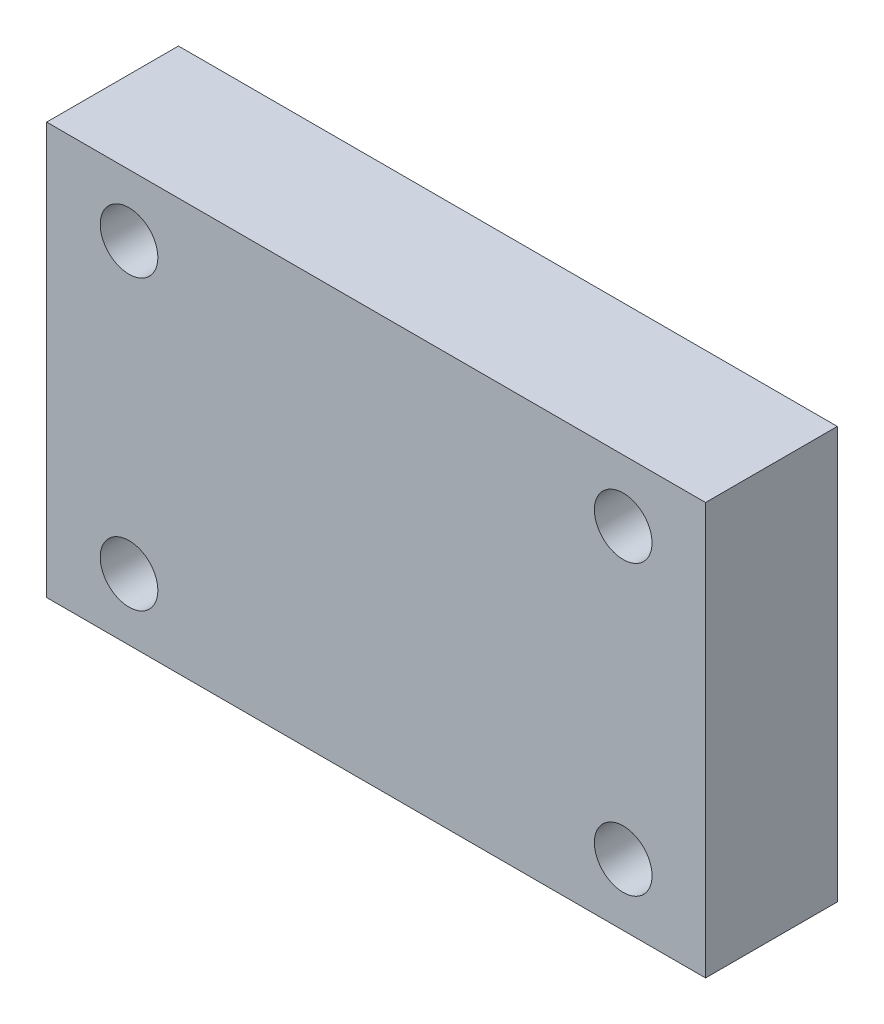
from build123d import *

# Parameters (mm, degrees)
ESQUISSE1_W             = 80
ESQUISSE1_H             = 50
BOSS_EXTRU_1_DEPTH      = 8
ESQUISSE2_R             = 3.5
ENL_V_MAT_EXTRU_1_DEPTH = 17


with BuildPart() as part:
    # Esquisse1 → Boss.-Extru.1 (new body, symmetric)
    with BuildSketch(Plane.XY):
        Rectangle(ESQUISSE1_W, ESQUISSE1_H)
    extrude(amount=BOSS_EXTRU_1_DEPTH, both=True)

    # Esquisse2 → Enlèv. mat.-Extru.1 (cut, through all)
    with BuildSketch(Plane.XY.offset(8)):
        with Locations((-30, 17.5)):
            Circle(ESQUISSE2_R)
        with Locations(Location((30, 17.5, 0), (0, 0, 180))):  # turned: the seam where the file's is
            Circle(ESQUISSE2_R)
        with Locations((-30, -17.5)):
            Circle(ESQUISSE2_R)
        with Locations((30, -17.5)):
            Circle(ESQUISSE2_R)
    extrude(amount=-ENL_V_MAT_EXTRU_1_DEPTH, mode=Mode.SUBTRACT)


solid = part.part
